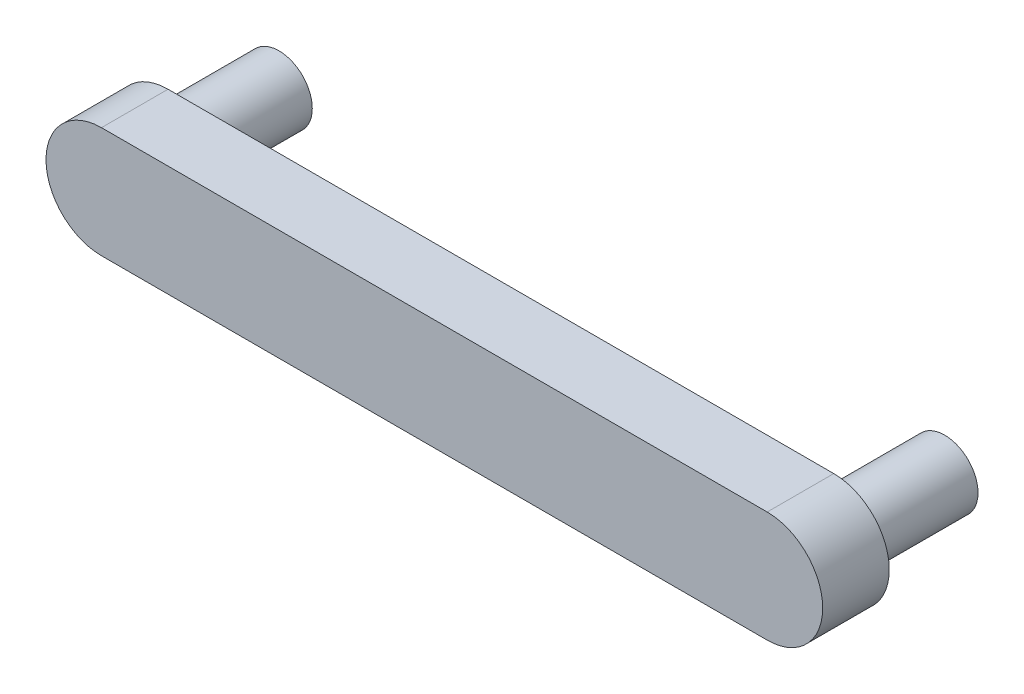
from build123d import *

# Parameters (mm, degrees)
BOSS_EXTRUDE1_DEPTH = 3
SKETCH3_R           = 1.5
BOSS_EXTRUDE2_DEPTH = 5


with BuildPart() as part:
    # Sketch1 → Boss-Extrude1 (new body)
    with BuildSketch(Plane.XY):
        with BuildLine():
            Line((-15, -2.5), (15, -2.5))
            ThreePointArc((15, -2.5), (17.5, 0), (15, 2.5))
            Line((15, 2.5), (-15, 2.5))
            ThreePointArc((-15, 2.5), (-17.5, 0), (-15, -2.5))
        make_face()
    extrude(amount=BOSS_EXTRUDE1_DEPTH)

    # Sketch3 → Boss-Extrude2 (add)
    with BuildSketch(Plane.XY):
        with Locations((-15, 0)):
            Circle(SKETCH3_R)
        with Locations((15, 0)):
            Circle(SKETCH3_R)
    extrude(amount=-BOSS_EXTRUDE2_DEPTH)


solid = part.part
